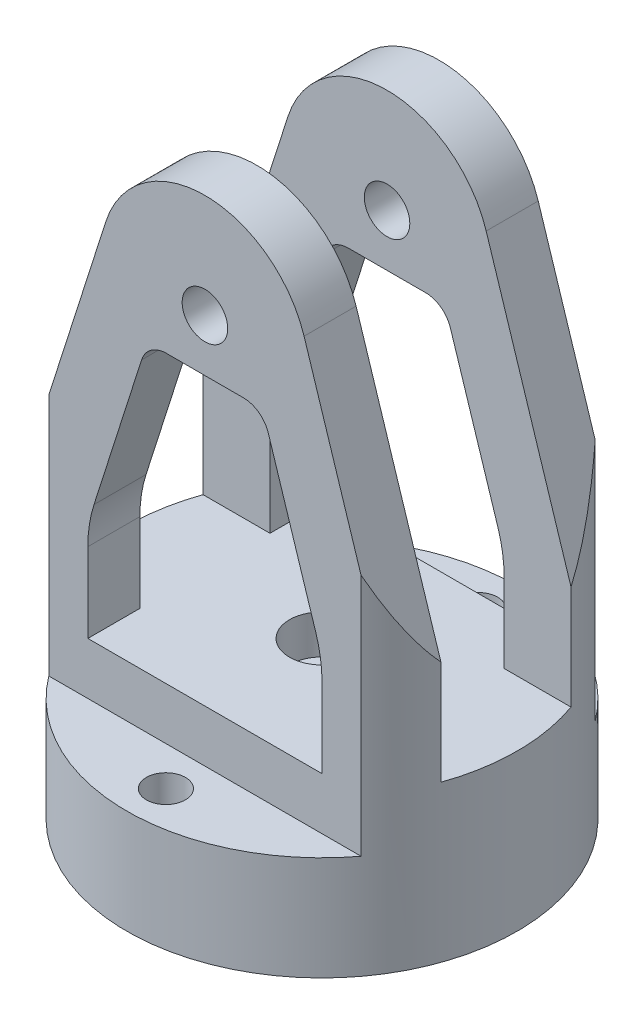
from build123d import *

# Parameters (mm, degrees)
CUT_EXTRUDE1_DEPTH      = 120.65
CUT_EXTRUDE2_DEPTH      = 107.95
CUT_EXTRUDE3_DEPTH      = 167.225729431
CUT_EXTRUDE3_DEPTH_BACK = 167.225729431
SKETCH5_R               = 4.7625
CUT_EXTRUDE4_DEPTH      = 139.176350183


with BuildPart() as part:
    # Sketch1 → Revolve1 (revolve)
    with BuildSketch(Plane(origin=(0, 0, 0), x_dir=(0, 0, -1), z_dir=(1, 0, 0))):
        Polygon((0, 0), (47.625, 0), (47.625, 146.05), (0, 146.05), (0, 38.1), (7.9375, 38.1), (7.9375, 28.575), (0, 28.575), align=None)
    revolve(axis=Axis((0, 0, 0), (0, 1, 0)))

    # Sketch2 → Cut-Extrude1 (cut)
    with BuildSketch(Plane(origin=(0, 146.05, 0), x_dir=(1, 0, 0), z_dir=(0, 1, 0))):
        with BuildLine():
            ThreePointArc((38.1, 28.575), (0, 47.625), (-38.1, 28.575))
            Line((-38.1, 28.575), (38.1, 28.575))
        make_face()
        with BuildLine():
            Line((38.1, -28.575), (-38.1, -28.575))
            ThreePointArc((-38.1, -28.575), (0, -47.625), (38.1, -28.575))
        make_face()
    extrude(amount=-CUT_EXTRUDE1_DEPTH, mode=Mode.SUBTRACT)

    # Sketch2_3 → Cut-Extrude2 (cut)
    with BuildSketch(Plane(origin=(0, 146.05, 0), x_dir=(1, 0, 0), z_dir=(0, 1, 0))):
        with BuildLine():
            ThreePointArc((-44.901280605, 15.875), (-46.939131403, 8.053481737), (-47.625, 0))
            Line((-47.625, 0), (47.625, 0))
            ThreePointArc((47.625, 0), (46.939131403, 8.053481737), (44.901280605, 15.875))
            Line((44.901280605, 15.875), (-44.901280605, 15.875))
        make_face()
        with BuildLine():
            Line((47.625, 0), (-47.625, 0))
            ThreePointArc((-47.625, 0), (-46.939131403, -8.053481737), (-44.901280605, -15.875))
            Line((-44.901280605, -15.875), (44.901280605, -15.875))
            ThreePointArc((44.901280605, -15.875), (46.939131403, -8.053481737), (47.625, 0))
        make_face()
    extrude(amount=-CUT_EXTRUDE2_DEPTH, mode=Mode.SUBTRACT)

    # Sketch4 → Cut-Extrude3 (cut, two sides)
    with BuildSketch(Plane.XY.offset(-15.875)) as cut_extrude3_sk:
        with BuildLine():
            Line((-28.575, 57.498647721), (-28.575, 38.1))
            Line((-28.575, 38.1), (0, 38.1))
            Line((0, 38.1), (0, 107.95))
            Line((0, 107.95), (-9.412473661, 107.95))
            ThreePointArc((-9.412473661, 107.95), (-13.158337818, 106.72747518), (-15.461867516, 103.530630463))
            Line((-15.461867516, 103.530630463), (-27.071969275, 67.151800038))
            ThreePointArc((-27.071969275, 67.151800038), (-28.196992083, 62.38338034), (-28.575, 57.498647721))
        make_face()
        with BuildLine():
            Line((0, 107.95), (0, 38.1))
            Line((0, 38.1), (28.575, 38.1))
            Line((28.575, 38.1), (28.575, 57.498647721))
            ThreePointArc((28.575, 57.498647721), (28.196992083, 62.38338034), (27.071969275, 67.151800038))
            Line((27.071969275, 67.151800038), (15.461867516, 103.530630463))
            ThreePointArc((15.461867516, 103.530630463), (13.158337818, 106.72747518), (9.412473661, 107.95))
            Line((9.412473661, 107.95), (0, 107.95))
        make_face()
        with BuildLine():
            Line((-44.901280605, 146.05), (-44.901280605, 63.5))
            Line((-44.901280605, 63.5), (-24.19757542, 128.372521853))
            ThreePointArc((-24.19757542, 128.372521853), (-14.983456626, 141.15990072), (0, 146.05))
            Line((0, 146.05), (-44.901280605, 146.05))
        make_face()
        with BuildLine():
            Line((44.901280605, 146.05), (0, 146.05))
            ThreePointArc((0, 146.05), (14.983456626, 141.15990072), (24.19757542, 128.372521853))
            Line((24.19757542, 128.372521853), (44.901280605, 63.5))
            Line((44.901280605, 63.5), (44.901280605, 146.05))
        make_face()
        with BuildLine():
            ThreePointArc((5.55625, 120.65), (3.928862053, 124.578862053), (0, 126.20625))
            Line((0, 126.20625), (0, 115.09375))
            ThreePointArc((0, 115.09375), (3.928862053, 116.721137947), (5.55625, 120.65))
        make_face()
        with BuildLine():
            Line((0, 115.09375), (0, 126.20625))
            ThreePointArc((0, 126.20625), (-5.55625, 120.65), (0, 115.09375))
        make_face()
    extrude(amount=CUT_EXTRUDE3_DEPTH, mode=Mode.SUBTRACT)
    extrude(cut_extrude3_sk.sketch, amount=-CUT_EXTRUDE3_DEPTH_BACK, mode=Mode.SUBTRACT)

    # Sketch5 → Cut-Extrude4 (cut, through all)
    with BuildSketch(Plane(origin=(0, 25.4, 0), x_dir=(1, 0, 0), z_dir=(0, 1, 0))):
        with Locations(Location((0, -38.1, 0), (0, 0, 270))):
            Circle(SKETCH5_R)
        with Locations(Location((0, 38.1, 0), (0, 0, 90))):
            Circle(SKETCH5_R)
    extrude(amount=-CUT_EXTRUDE4_DEPTH, mode=Mode.SUBTRACT)


solid = part.part
